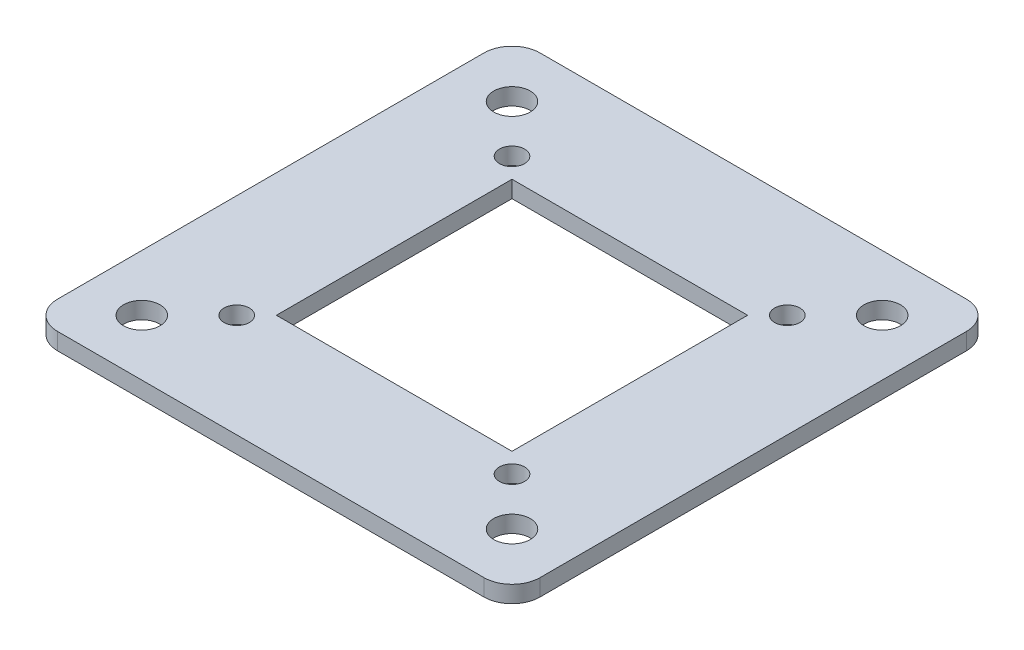
from build123d import *

# Parameters (mm, degrees)
SKETCH2_W           = 86
SKETCH2_H           = 86
SKETCH2_W_2         = 42
SKETCH2_H_2         = 42
BOSS_EXTRUDE1_DEPTH = 3
SKETCH3_R           = 3.25
CUT_EXTRUDE1_DEPTH  = 3
SKETCH7_R           = 2.25
CUT_EXTRUDE2_DEPTH  = 3
FILLET1_R           = 5
FILLET2_R           = 5
FILLET3_R           = 5
FILLET4_R           = 5


with BuildPart() as part:
    # Sketch2 → Boss-Extrude1 (new body)
    with BuildSketch(Plane(origin=(0, 0, 0), x_dir=(1, 0, 0), z_dir=(0, 1, 0))):
        with Locations((1.854851242, 27.411515707)):
            Rectangle(SKETCH2_W, SKETCH2_H)
        with Locations((1.854851242, 27.411515707)):
            Rectangle(SKETCH2_W_2, SKETCH2_H_2, mode=Mode.SUBTRACT)
    extrude(amount=BOSS_EXTRUDE1_DEPTH)

    # Sketch3 → Cut-Extrude1 (cut)
    with BuildSketch(Plane(origin=(0, 3, 0), x_dir=(1, 0, 0), z_dir=(0, 1, 0))):
        with Locations((34.854851242, -5.588484293)):
            Circle(SKETCH3_R)
        with Locations((-31.145148758, -5.588484293)):
            Circle(SKETCH3_R)
        with Locations((-31.145148758, 60.411515707)):
            Circle(SKETCH3_R)
        with Locations((34.854851242, 60.411515707)):
            Circle(SKETCH3_R)
    extrude(amount=-CUT_EXTRUDE1_DEPTH, mode=Mode.SUBTRACT)

    # Sketch7 → Cut-Extrude2 (cut)
    with BuildSketch(Plane(origin=(0, 3, 0), x_dir=(1, 0, 0), z_dir=(0, 1, 0))):
        with Locations((26.390385148, 2.875981801)):
            Circle(SKETCH7_R)
        with Locations((-22.680682664, 2.875981801)):
            Circle(SKETCH7_R)
        with Locations((-22.680682664, 51.947049613)):
            Circle(SKETCH7_R)
        with Locations((26.390385148, 51.947049613)):
            Circle(SKETCH7_R)
    extrude(amount=-CUT_EXTRUDE2_DEPTH, mode=Mode.SUBTRACT)

    # Fillet1
    fillet1_edges = [part.edges().sort_by_distance(p)[0] for p in [
        (-41.145148758, 1.5, -70.411515707),
    ]]
    fillet(fillet1_edges, radius=FILLET1_R)

    # Fillet2
    fillet2_edges = [part.edges().sort_by_distance(p)[0] for p in [
        (44.854851242, 1.5, 15.588484293),
    ]]
    fillet(fillet2_edges, radius=FILLET2_R)

    # Fillet3
    fillet3_edges = [part.edges().sort_by_distance(p)[0] for p in [
        (-41.145148758, 1.5, 15.588484293),
    ]]
    fillet(fillet3_edges, radius=FILLET3_R)

    # Fillet4
    fillet4_edges = [part.edges().sort_by_distance(p)[0] for p in [
        (44.854851242, 1.5, -70.411515707),
    ]]
    fillet(fillet4_edges, radius=FILLET4_R)


solid = part.part
